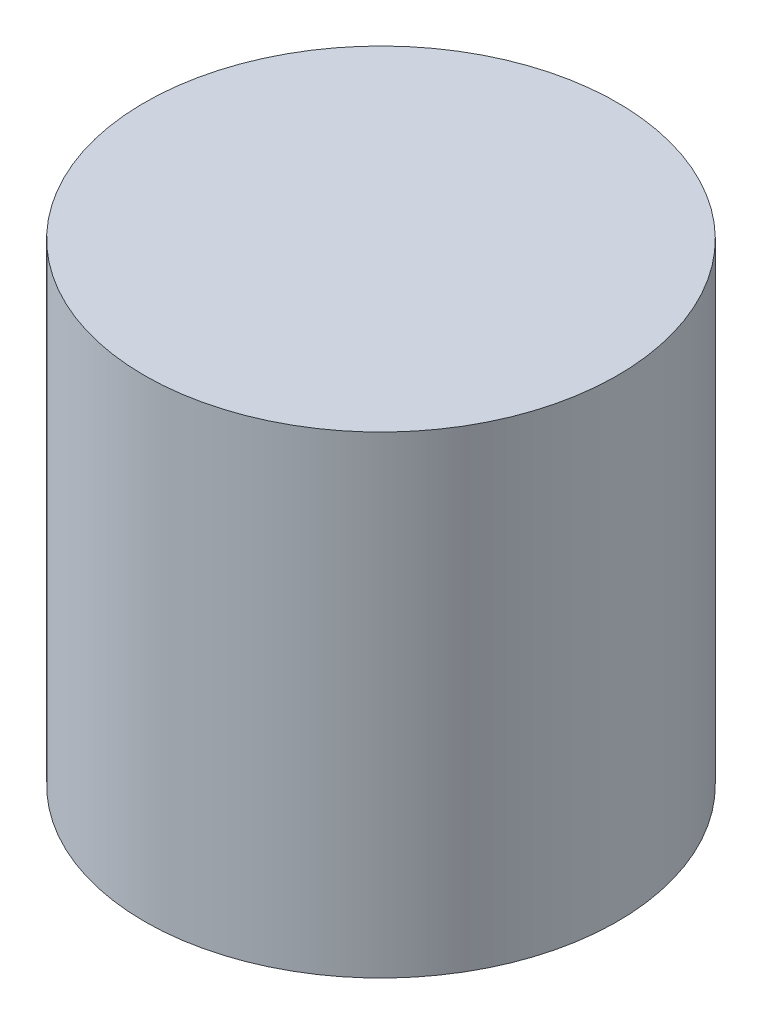
from build123d import *

# Parameters (mm, degrees)
SKETCH1_R           = 76.2
BOSS_EXTRUDE1_DEPTH = 152.4


with BuildPart() as part:
    # Sketch1 → Boss-Extrude1 (new body)
    with BuildSketch(Plane(origin=(0, 0, 0), x_dir=(1, 0, 0), z_dir=(0, 1, 0))):
        Circle(SKETCH1_R)
    extrude(amount=BOSS_EXTRUDE1_DEPTH)


solid = part.part
